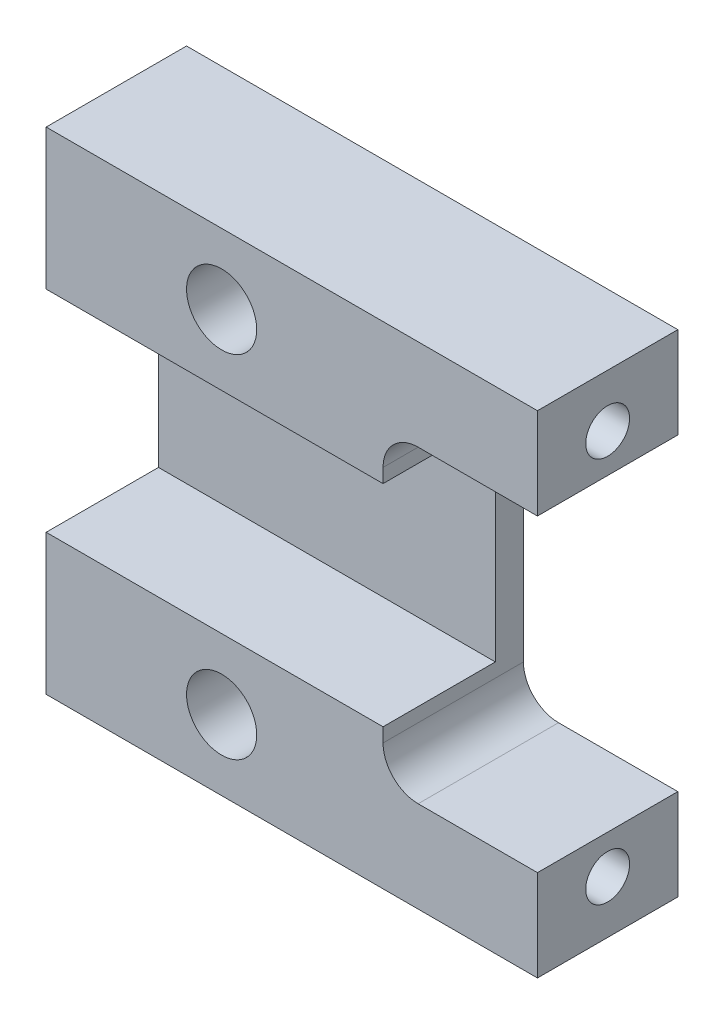
from build123d import *

# Parameters (mm, degrees)
SKETCH1_W                  = 88.9
SKETCH1_H                  = 88.9
EXTRUDE1_DEPTH             = 25.4
F_1_2_0_5_DIAMETER_HOLE1_D = 12.7
EXTRUDE5_DEPTH             = 20.32
SKETCH16_W                 = 27.94
SKETCH16_H                 = 55.88
EXTRUDE6_DEPTH             = 6.08
FILLET2_R                  = 6.35


with BuildPart() as part:
    # Sketch1 → Extrude1 (new body)
    with BuildSketch(Plane.XY):
        Rectangle(SKETCH1_W, SKETCH1_H)
    extrude(amount=EXTRUDE1_DEPTH)

    # Sketch3 → Tap Drill for 3/8-16 Tap2 (revolve, cut)
    with BuildSketch(Plane(origin=(44.45, 34.925, 12.7), x_dir=(0, 0, -1), z_dir=(0, 1, 0))):
        Polygon((0, 0), (0, 20.164665582), (3.96875, 17.78), (3.96875, 0), align=None)
    tap_drill_for_3_8_16_tap2 = revolve(axis=Axis((50.8, 34.925, 12.7), (-1, 0, 0)), mode=Mode.SUBTRACT)

    # Mirror1: Tap Drill for 3/8-16 Tap2 across plane
    add(tap_drill_for_3_8_16_tap2.mirror(Plane.ZX), mode=Mode.SUBTRACT)

    # 1/2 (0.5) Diameter Hole1 (through all)
    with Locations(Plane.XY.offset(25.4)):
        with Locations((-12.7, 31.75)):
            f_1_2_0_5_diameter_hole1 = Hole(F_1_2_0_5_DIAMETER_HOLE1_D / 2)

    # Mirror3: 1/2 (0.5) Diameter Hole1 across plane
    add(f_1_2_0_5_diameter_hole1.mirror(Plane.ZX), mode=Mode.SUBTRACT)

    # Sketch15 → Extrude5 (cut)
    with BuildSketch(Plane.XY.offset(25.4)):
        Polygon((-44.45, 0), (-44.45, 19.05), (16.51, 19.05), (16.51, 27.94), (44.45, 27.94), (44.45, 0), align=None)
    extrude5 = extrude(amount=-EXTRUDE5_DEPTH, mode=Mode.SUBTRACT)

    # Mirror4: Extrude5 across plane
    add(extrude5.mirror(Plane.ZX), mode=Mode.SUBTRACT)

    # Sketch16 → Extrude6 (cut, through all)
    with BuildSketch(Plane.XY.offset(5.08)):
        with Locations((30.48, 0)):
            Rectangle(SKETCH16_W, SKETCH16_H)
    extrude(amount=-EXTRUDE6_DEPTH, mode=Mode.SUBTRACT)

    # Fillet2
    fillet2_edges = [part.edges().sort_by_distance(p)[0] for p in [
        (16.51, 27.94, 12.7),
        (16.51, -27.94, 12.7),
    ]]
    fillet(fillet2_edges, radius=FILLET2_R)

    # Sketch18 → Tap Drill for 1/2-13 Tap2 (revolve, cut)
    with BuildSketch(Plane(origin=(-44.45, 31.75, 12.7), x_dir=(0, 0, 1), z_dir=(0, 1, 0))):
        Polygon((0, 0), (0, 20.999489309), (5.35813, 17.78), (5.35813, 0), align=None)
    tap_drill_for_1_2_13_tap2 = revolve(axis=Axis((-50.8, 31.75, 12.7), (1, 0, 0)), mode=Mode.SUBTRACT)

    # Mirror5: Tap Drill for 1/2-13 Tap2 across plane
    add(tap_drill_for_1_2_13_tap2.mirror(Plane.ZX), mode=Mode.SUBTRACT)


solid = part.part
